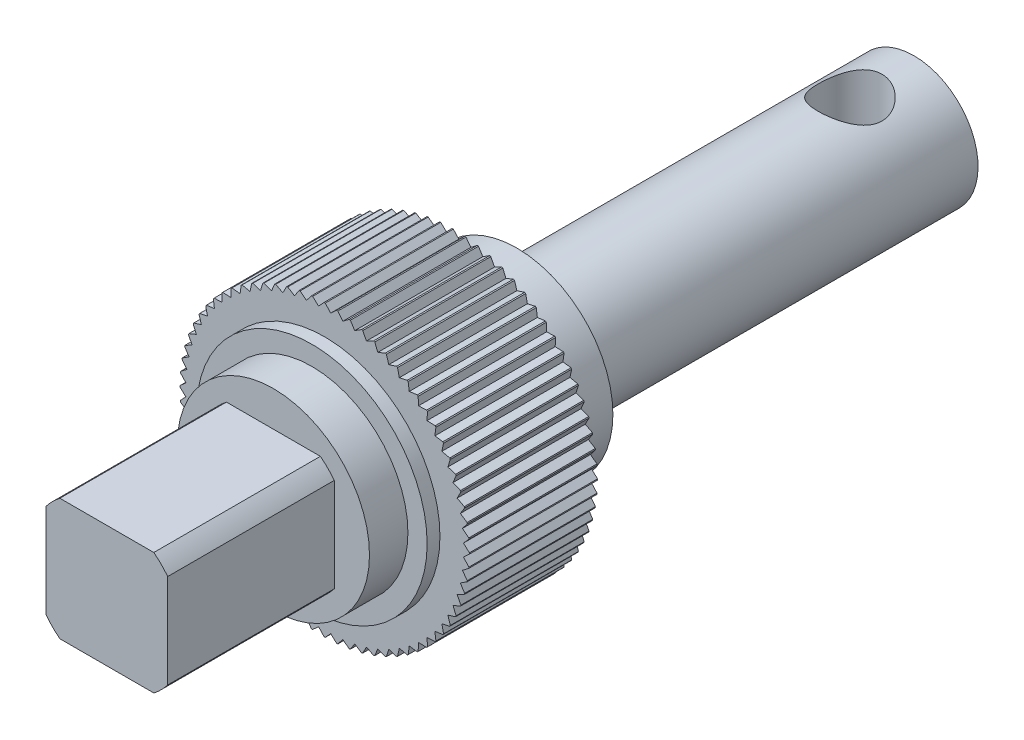
from build123d import *

# Parameters (mm, degrees)
SKETCH_1_R               = 10.8
EXTRUDE_1_DEPTH          = 10
EXTRUDE_2_DEPTH          = 10
PATTERN_CIRCULAR_1_COUNT = 72
SKETCH_6_R               = 2.5
CUT_EXTRUDE_1_DEPTH      = 5
SKETCH_7_OUTSIDE_W       = 38.842
SKETCH_7_OUTSIDE_H       = 38.842
SKETCH_7_OUTSIDE_W_2     = 9.5
SKETCH_7_OUTSIDE_H_2     = 9.5
CUT_EXTRUDE_2_DEPTH      = 20
SKETCH_8_R               = 9
EXTRUDE_3_DEPTH          = 1
SKETCH_10_R              = 16.65876012
SKETCH_10_R_2            = 11.3
CUT_EXTRUDE_4_DEPTH      = 47.0000001


with BuildPart() as part:
    # 草图1 → 凸台-拉伸1 (new body)
    with BuildSketch(Plane.XY):
        Circle(SKETCH_1_R)
    extrude(amount=EXTRUDE_1_DEPTH)

    # 草图2 → 凸台-拉伸2 (add)
    with BuildSketch(Plane.XY.offset(10)):
        Polygon((0, 11.35), (-0.515251108, 10.787702086), (0.515251108, 10.787702086), align=None)
    extrude_2 = extrude(amount=-EXTRUDE_2_DEPTH)

    # 阵列(圆周)1: 凸台-拉伸2 ×72 about axis
    pattern_circular_1_axis = Axis((0, 0, 0), (0, 0, 1))
    for i in range(1, PATTERN_CIRCULAR_1_COUNT):
        add(extrude_2.rotate(pattern_circular_1_axis, i * 360 / PATTERN_CIRCULAR_1_COUNT))

    # 草图4 → 旋转1 (revolve)
    with BuildSketch(Plane(origin=(0, 0, 0), x_dir=(0, 0, -1), z_dir=(1, 0, 0))):
        Polygon((-27, 0), (-27, 6), (-14, 6), (-14, 7.5), (5, 7.5), (5, 5), (36, 5), (36, 0), align=None)
    revolve(axis=Axis((0, 0, 0), (0, 0, 1)))

    # 草图6 → 切除-拉伸1 (cut, symmetric)
    with BuildSketch(Plane(origin=(0, 0, 0), x_dir=(1, 0, 0), z_dir=(0, 1, 0))):
        with Locations((0, 31)):
            Circle(SKETCH_6_R)
    extrude(amount=CUT_EXTRUDE_1_DEPTH, both=True, mode=Mode.SUBTRACT)

    # 草图7 outside → 切除-拉伸2 (cut)
    with BuildSketch(Plane.XY.offset(14)):
        Rectangle(SKETCH_7_OUTSIDE_W, SKETCH_7_OUTSIDE_H)
        Rectangle(SKETCH_7_OUTSIDE_W_2, SKETCH_7_OUTSIDE_H_2, mode=Mode.SUBTRACT)
    extrude(amount=CUT_EXTRUDE_2_DEPTH, mode=Mode.SUBTRACT)

    # 草图8 → 凸台-拉伸3 (add)
    with BuildSketch(Plane.XY.offset(10)):
        Circle(SKETCH_8_R)
    extrude(amount=EXTRUDE_3_DEPTH)

    # 草图10 → 切除-拉伸4 (cut, through all)
    with BuildSketch(Plane.XY.offset(10)):
        Circle(SKETCH_10_R)
        Circle(SKETCH_10_R_2, mode=Mode.SUBTRACT)
    extrude(amount=-CUT_EXTRUDE_4_DEPTH, mode=Mode.SUBTRACT)


solid = part.part
